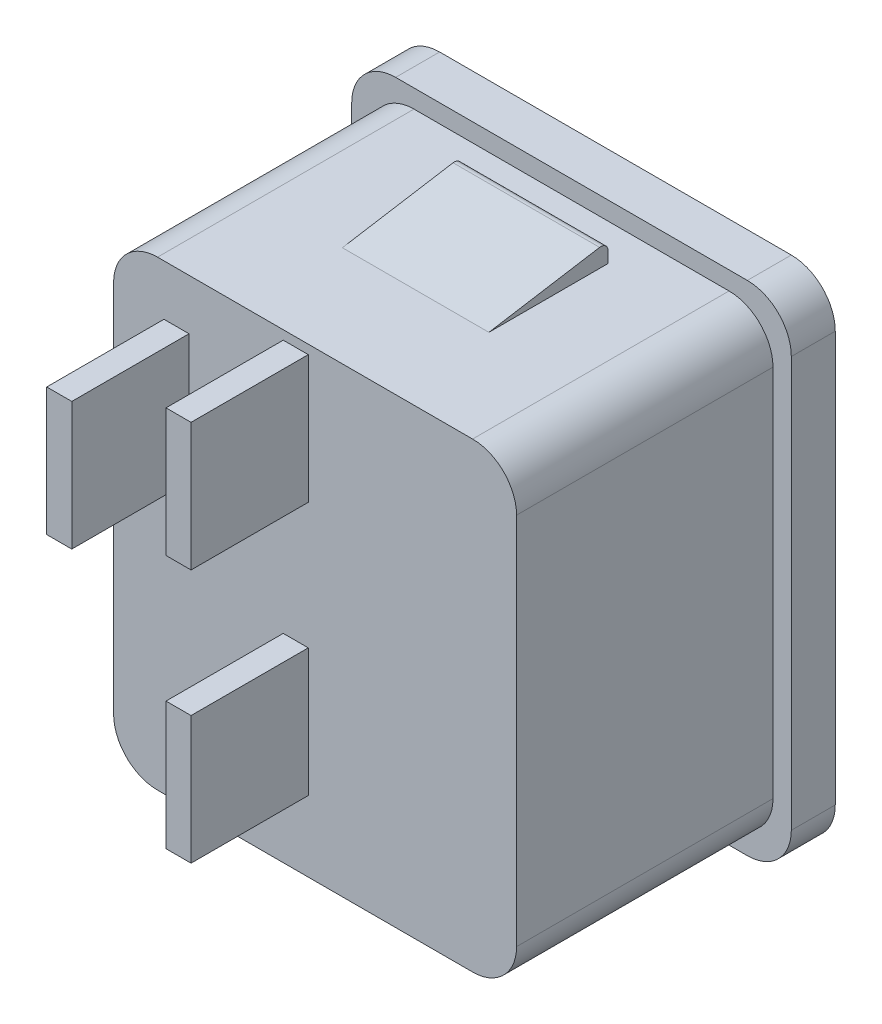
from build123d import *

# Parameters (mm, degrees)
SKETCH1_W           = 30
SKETCH1_H           = 34
BOSS_EXTRUDE1_DEPTH = 3
SKETCH3_W           = 27.5
SKETCH3_H           = 31.5
BOSS_EXTRUDE2_DEPTH = 25.5
FILLET1_R           = 3
BOSS_EXTRUDE3_DEPTH = 5
SKETCH5_OUTSIDE_W   = 42.712
SKETCH5_OUTSIDE_H   = 46.712
SKETCH5_OUTSIDE_W_2 = 1.709929724
SKETCH5_OUTSIDE_H_2 = 8.726730488
CUT_EXTRUDE1_DEPTH  = 8


with BuildPart() as part:
    # Sketch1 → Boss-Extrude1 (new body)
    with BuildSketch(Plane.XY):
        Rectangle(SKETCH1_W, SKETCH1_H)
    extrude(amount=-BOSS_EXTRUDE1_DEPTH)

    # Sketch3 → Boss-Extrude2 (add)
    with BuildSketch(Plane.XY):
        Rectangle(SKETCH3_W, SKETCH3_H)
    extrude(amount=BOSS_EXTRUDE2_DEPTH)

    # Fillet1
    fillet1_edges = [part.edges().sort_by_distance(p)[0] for p in [
        (13.75, -15.75, 12.75),
        (13.75, 15.75, 12.75),
        (-13.75, 15.75, 12.75),
        (-13.75, -15.75, 12.75),
        (15, -17, -1.5),
        (-15, -17, -1.5),
        (-15, 17, -1.5),
        (15, 17, -1.5),
    ]]
    fillet(fillet1_edges, radius=FILLET1_R)

    # Sketch4 → Boss-Extrude3 (add, symmetric)
    with BuildSketch(Plane(origin=(0, 0, 0), x_dir=(0, 0, -1), z_dir=(1, 0, 0))):
        with BuildLine():
            Line((-2.5, 15.75), (-2.5, 16.5))
            ThreePointArc((-2.5, 16.5), (-2.676424395, 16.881180834), (-3.081195313, 16.993363275))
            Line((-3.081195313, 16.993363275), (-10.636185348, 15.75))
            Line((-10.636185348, 15.75), (-2.5, 15.75))
        make_face()
        with BuildLine():
            Line((-2.5, -15.75), (-10.636185348, -15.75))
            Line((-10.636185348, -15.75), (-3.081195313, -16.993363275))
            ThreePointArc((-3.081195313, -16.993363275), (-2.676424395, -16.881180834), (-2.5, -16.5))
            Line((-2.5, -16.5), (-2.5, -15.75))
        make_face()
    extrude(amount=BOSS_EXTRUDE3_DEPTH, both=True)

    # Sketch5 outside → Cut-Extrude1 (cut)
    with BuildSketch(Plane.XY.offset(25.5)):
        Rectangle(SKETCH5_OUTSIDE_W, SKETCH5_OUTSIDE_H)
        with Locations((-9.457120396, 7.933102862)):
            Rectangle(SKETCH5_OUTSIDE_W_2, SKETCH5_OUTSIDE_H_2, mode=Mode.SUBTRACT)
        with Locations((-1.31810636, 10.768093543)):
            Rectangle(SKETCH5_OUTSIDE_W_2, SKETCH5_OUTSIDE_H_2, mode=Mode.SUBTRACT)
        with Locations((-1.31810636, -6.561253842)):
            Rectangle(SKETCH5_OUTSIDE_W_2, SKETCH5_OUTSIDE_H_2, mode=Mode.SUBTRACT)
    extrude(amount=-CUT_EXTRUDE1_DEPTH, mode=Mode.SUBTRACT)


solid = part.part
